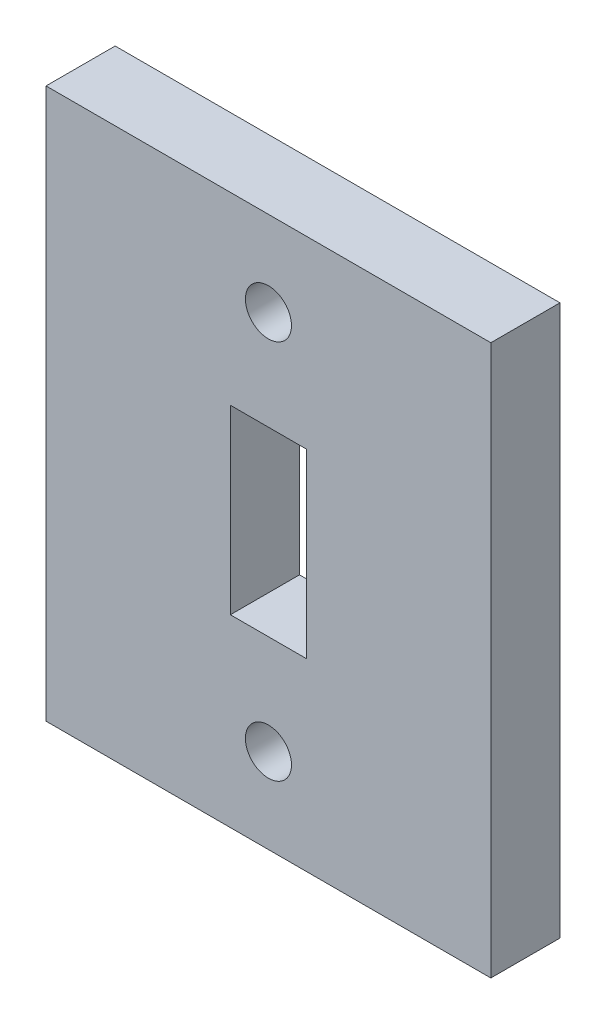
from build123d import *

# Parameters (mm, degrees)
SKETCH1_W           = 19.302
SKETCH1_H           = 23.874
SKETCH1_W_2         = 3.302
SKETCH1_H_2         = 7.874
BOSS_EXTRUDE1_DEPTH = 3
SKETCH3_R           = 1
CUT_EXTRUDE1_DEPTH  = 4


with BuildPart() as part:
    # Sketch1 → Boss-Extrude1 (new body)
    with BuildSketch(Plane.XY):
        with Locations((9.651, 11.937)):
            Rectangle(SKETCH1_W, SKETCH1_H)
        with Locations((9.651, 11.937)):
            Rectangle(SKETCH1_W_2, SKETCH1_H_2, mode=Mode.SUBTRACT)
    extrude(amount=BOSS_EXTRUDE1_DEPTH)

    # Sketch3 → Cut-Extrude1 (cut, through all)
    with BuildSketch(Plane(origin=(0, 0, 0), x_dir=(-1, 0, 0), z_dir=(0, 0, -1))):
        with Locations((-9.651, 20.192)):
            Circle(SKETCH3_R)
        with Locations((-9.651, 3.682)):
            Circle(SKETCH3_R)
    extrude(amount=-CUT_EXTRUDE1_DEPTH, mode=Mode.SUBTRACT)


solid = part.part
